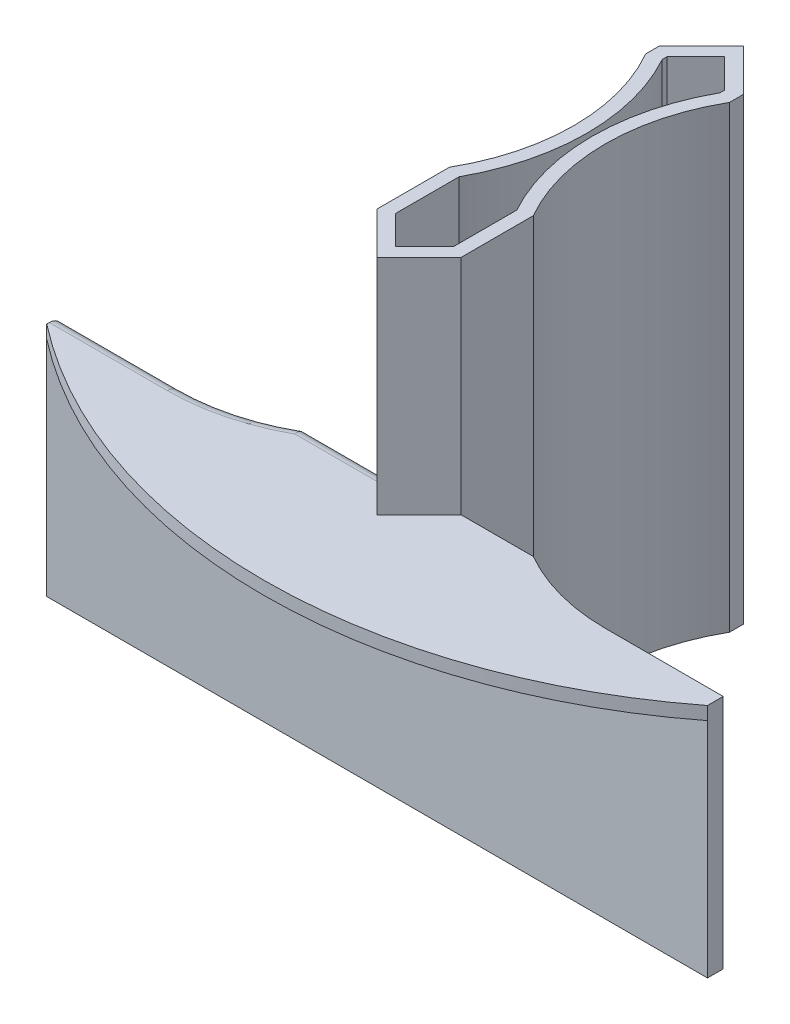
from build123d import *

# Parameters (mm, degrees)
BOSS_EXTRUDE2_START     = -9.15
BOSS_EXTRUDE2_DEPTH     = 111.125
CUT_EXTRUDE2_DEPTH      = 53.975
SKETCH16_R              = 1.349999967
CUT_EXTRUDE3_DEPTH      = 112.125
CUT_EXTRUDE4_DEPTH      = 112.125000012
SKETCH22_R              = 1.849999983
CUT_EXTRUDE7_DEPTH      = 102.975000012
CUT_EXTRUDE7_DEPTH_BACK = 10.15
SKETCH23_W              = 28.575
SKETCH23_H              = 3.81
BOSS_EXTRUDE3_DEPTH     = 57.15
BOSS_EXTRUDE4_DEPTH     = 3.175
FILLET1_R               = 3.175
CUT_EXTRUDE8_DEPTH      = 112.125000012
CUT_EXTRUDE9_DEPTH      = 53.975
CUT_EXTRUDE12_DEPTH     = 82.55


with BuildPart() as part:
    # Sketch13 → Boss-Extrude2 (new body)
    with BuildSketch(Plane(origin=(0, 0, 0), x_dir=(1, 0, 0), z_dir=(0, 1, 0)).offset(BOSS_EXTRUDE2_START)):
        with BuildLine():
            Line((-51.435, -51.435), (0, -51.435))
            Line((0, -51.435), (0, -47.625))
            ThreePointArc((0, -47.625), (-12.296722124, -46.010121169), (-23.759524406, -41.275))
            Line((-23.759524406, -41.275), (-41.275, -41.275))
            Line((-41.275, -41.275), (-41.275, -23.759524406))
            ThreePointArc((-41.275, -23.759524406), (-47.625, 0), (-41.275, 23.759524406))
            Line((-41.275, 23.759524406), (-41.275, 41.275))
            Line((-41.275, 41.275), (-51.435, 51.435))
            Line((-51.435, 51.435), (-51.435, -51.435))
        make_face()
    boss_extrude2 = extrude(amount=BOSS_EXTRUDE2_DEPTH)

    # Sketch15 → Cut-Extrude2 (cut)
    with BuildSketch(Plane(origin=(0, 101.975000012, 0), x_dir=(1, 0, 0), z_dir=(0, 1, 0))):
        Polygon((0, 0), (-51.435, -51.435), (0, -51.435), align=None)
    cut_extrude2 = extrude(amount=-CUT_EXTRUDE2_DEPTH, mode=Mode.SUBTRACT)

    # Mirror1: Boss-Extrude2, Cut-Extrude2 across plane
    add(boss_extrude2.mirror(Plane(origin=(-51.435, 101.975000012, 51.435), x_dir=(0, 0, 1), z_dir=(1, 0, 0))))
    add(cut_extrude2.mirror(Plane(origin=(-51.435, 101.975000012, 51.435), x_dir=(0, 0, 1), z_dir=(1, 0, 0))), mode=Mode.SUBTRACT)

    # Sketch16 → Cut-Extrude3 (cut, through all)
    with BuildSketch(Plane.XZ.offset(9.149999988)):
        with Locations((-51.435, -13.335)):
            Circle(SKETCH16_R)
    extrude(amount=-CUT_EXTRUDE3_DEPTH, mode=Mode.SUBTRACT)

    # Sketch17 → Cut-Extrude4 (cut, through all)
    with BuildSketch(Plane(origin=(0, 101.975000012, 0), x_dir=(1, 0, 0), z_dir=(0, 1, 0))):
        Polygon((7.094402336, 7.094402336), (-7.094402336, -7.094402336), (-51.435, 37.246195329), (-95.775597664, -7.094402336), (-109.964402336, 7.094402336), (-58.529402336, 58.529402336), (-51.435, 51.435), (-44.340597664, 58.529402336), align=None)
    extrude(amount=-CUT_EXTRUDE4_DEPTH, mode=Mode.SUBTRACT)

    # Sketch22 → Cut-Extrude7 (cut, two sides)
    with BuildSketch(Plane(origin=(0, 0, 0), x_dir=(1, 0, 0), z_dir=(0, 1, 0))) as cut_extrude7_sk:
        with Locations((-51.435, -12.065)):
            Circle(SKETCH22_R)
    extrude(amount=CUT_EXTRUDE7_DEPTH, mode=Mode.SUBTRACT)
    extrude(cut_extrude7_sk.sketch, amount=-CUT_EXTRUDE7_DEPTH_BACK, mode=Mode.SUBTRACT)

    # Sketch23 → Boss-Extrude3 (add)
    with BuildSketch(Plane(origin=(0, 48.000000012, 0), x_dir=(1, 0, 0), z_dir=(0, 1, 0))):
        with Locations((14.2875, -49.53)):
            Rectangle(SKETCH23_W, SKETCH23_H)
        with Locations((-117.1575, -49.53)):
            Rectangle(SKETCH23_W, SKETCH23_H)
    extrude(amount=-BOSS_EXTRUDE3_DEPTH)

    # Sketch24 → Boss-Extrude4 (add)
    with BuildSketch(Plane(origin=(0, 48.000000012, 0), x_dir=(1, 0, 0), z_dir=(0, 1, 0))):
        with BuildLine():
            Line((28.575, -51.435), (-131.445, -51.435))
            ThreePointArc((-131.445, -51.435), (-51.435, -78.887051089), (28.575, -51.435))
        make_face()
    extrude(amount=-BOSS_EXTRUDE4_DEPTH)

    # Fillet1
    fillet1_edges = [part.edges().sort_by_distance(p)[0] for p in [
        (-117.1575, 48.000000012, 47.625),
        (-70.352737797, 48.000000012, 41.275),
        (-90.573277876, 48.000000012, 46.010121169),
    ]]
    fillet(fillet1_edges, radius=FILLET1_R)

    # Sketch25 → Cut-Extrude8 (cut, through all)
    with BuildSketch(Plane(origin=(0, 101.975000012, 0), x_dir=(1, 0, 0), z_dir=(0, 1, 0))):
        with BuildLine():
            Line((-58.42, -24.593444248), (-58.42, -39.959871939))
            Line((-58.42, -39.959871939), (-51.435, -46.944871939))
            Line((-51.435, -46.944871939), (-44.45, -39.959871939))
            Line((-44.45, -39.959871939), (-44.45, -24.593444248))
            ThreePointArc((-44.45, -24.593444248), (-46.543928705, -20.354427055), (-48.234688479, -15.939097443))
            ThreePointArc((-48.234688479, -15.939097443), (-51.435, -17.089999983), (-54.635311521, -15.939097443))
            ThreePointArc((-54.635311521, -15.939097443), (-56.326071295, -20.354427055), (-58.42, -24.593444248))
        make_face()
        with BuildLine():
            Line((-44.45, 25.771067268), (-44.45, 24.593444248))
            ThreePointArc((-44.45, 24.593444248), (-46.450454829, 20.566848232), (-48.087042692, 16.379142993))
            ThreePointArc((-48.087042692, 16.379142993), (-51.435, 17.859999967), (-54.782957308, 16.379142993))
            ThreePointArc((-54.782957308, 16.379142993), (-56.419545171, 20.566848232), (-58.42, 24.593444248))
            Line((-58.42, 24.593444248), (-58.42, 25.771067268))
            Line((-58.42, 25.771067268), (-51.435, 32.756067268))
            Line((-51.435, 32.756067268), (-44.45, 25.771067268))
        make_face()
    extrude(amount=-CUT_EXTRUDE8_DEPTH, mode=Mode.SUBTRACT)

    # Sketch26 → Cut-Extrude9 (cut)
    with BuildSketch(Plane.XZ.offset(9.149999988)):
        with BuildLine():
            Line((-44.45, 44.45), (-48.26, 48.26))
            Line((-48.26, 48.26), (-15.862294916, 48.26))
            ThreePointArc((-15.862294916, 48.26), (-20.317375146, 46.560114553), (-24.593444248, 44.45))
            Line((-24.593444248, 44.45), (-44.45, 44.45))
        make_face()
        with BuildLine():
            Line((-58.42, 44.45), (-54.61, 48.26))
            Line((-54.61, 48.26), (-87.007705084, 48.26))
            ThreePointArc((-87.007705084, 48.26), (-82.552624854, 46.560114553), (-78.276555752, 44.45))
            Line((-78.276555752, 44.45), (-58.42, 44.45))
        make_face()
    extrude(amount=-CUT_EXTRUDE9_DEPTH, mode=Mode.SUBTRACT)

    # Sketch30 → Cut-Extrude12 (cut)
    with BuildSketch(Plane(origin=(0, 101.975000012, 0), x_dir=(1, 0, 0), z_dir=(0, 1, 0))):
        with BuildLine():
            Line((-44.45, 25.771067268), (-51.435, 32.756067268))
            Line((-51.435, 32.756067268), (-58.42, 25.771067268))
            Line((-58.42, 25.771067268), (-58.42, 24.593444248))
            ThreePointArc((-58.42, 24.593444248), (-52.07, 0), (-58.42, -24.593444248))
            Line((-58.42, -24.593444248), (-58.42, -39.959871939))
            Line((-58.42, -39.959871939), (-51.435, -46.944871939))
            Line((-51.435, -46.944871939), (-44.45, -39.959871939))
            Line((-44.45, -39.959871939), (-44.45, -24.593444248))
            ThreePointArc((-44.45, -24.593444248), (-50.8, 0), (-44.45, 24.593444248))
            Line((-44.45, 24.593444248), (-44.45, 25.771067268))
        make_face()
    extrude(amount=-CUT_EXTRUDE12_DEPTH, mode=Mode.SUBTRACT)


solid = part.part
